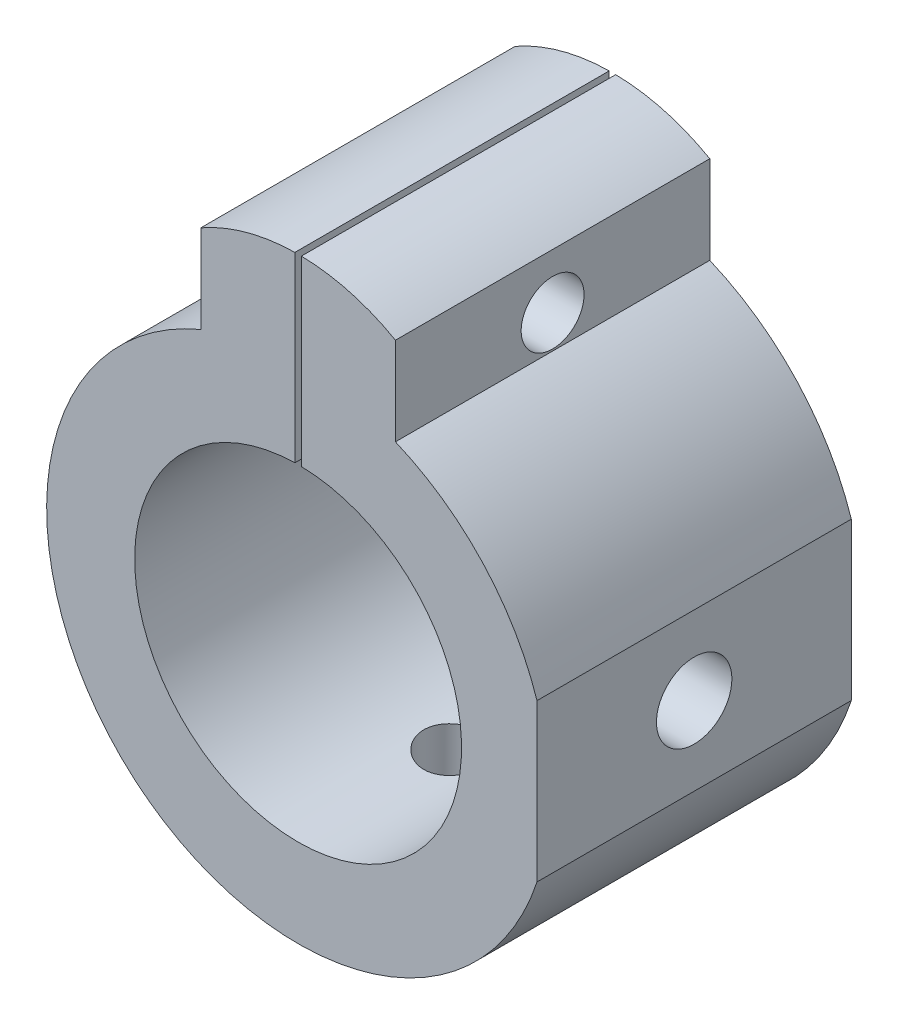
from build123d import *

# Parameters (mm, degrees)
SKETCH_1_R          = 3.5
SKETCH_1_R_2        = 13
EXTRUDE_2_DEPTH     = 10
SKETCH_2_R          = 13
EXTRUDE_3_DEPTH     = 15
SKETCH_3_W          = 0.517195108
SKETCH_3_H          = 18.726193104
CUT_EXTRUDE_1_DEPTH = 26
SKETCH_4_R          = 2.5
CUT_EXTRUDE_2_DEPTH = 43.740275714
CUT_EXTRUDE_3_DEPTH = 11
SKETCH_6_R          = 2.5
CUT_EXTRUDE_4_DEPTH = 21
SKETCH_8_W          = 5
SKETCH_8_H          = 30
CUT_EXTRUDE_5_DEPTH = 26.0000001
SKETCH_9_R          = 3
CUT_EXTRUDE_6_DEPTH = 10


with BuildPart() as part:
    # 草图1 → 凸台-拉伸2 (new body)
    with BuildSketch(Plane.XY):
        with BuildLine():
            Line((-35, -7), (-7.740275714, -18.44147857))
            ThreePointArc((-7.740275714, -18.44147857), (0, -20), (7.740275714, -18.44147857))
            Line((7.740275714, -18.44147857), (35, -7))
            Line((35, -7), (35, 7))
            Line((35, 7), (7.740275714, 18.44147857))
            Line((7.740275714, 18.44147857), (7.740275714, 25.44147857))
            ThreePointArc((7.740275714, 25.44147857), (0, 27.494244152), (-7.740275714, 25.44147857))
            Line((-7.740275714, 25.44147857), (-7.740275714, 18.44147857))
            Line((-7.740275714, 18.44147857), (-35, 7))
            Line((-35, 7), (-35, -7))
        make_face()
        with Locations((-28, 0)):
            Circle(SKETCH_1_R, mode=Mode.SUBTRACT)
        Circle(SKETCH_1_R_2, mode=Mode.SUBTRACT)
        with Locations((28, 0)):
            Circle(SKETCH_1_R, mode=Mode.SUBTRACT)
    extrude(amount=EXTRUDE_2_DEPTH)

    # 草图2 → 凸台-拉伸3 (add)
    with BuildSketch(Plane.XY.offset(10)):
        with BuildLine():
            Line((-7.740275714, 18.44147857), (-7.740275714, 25.44147857))
            ThreePointArc((-7.740275714, 25.44147857), (0, 27.494244152), (7.740275714, 25.44147857))
            Line((7.740275714, 25.44147857), (7.740275714, 18.44147857))
            ThreePointArc((7.740275714, 18.44147857), (0, -20), (-7.740275714, 18.44147857))
        make_face()
        Circle(SKETCH_2_R, mode=Mode.SUBTRACT)
    extrude(amount=EXTRUDE_3_DEPTH)

    # 草图3 → 切除-拉伸1 (cut, through all)
    with BuildSketch(Plane.XY.offset(25)):
        with Locations((0, 21.741202931)):
            Rectangle(SKETCH_3_W, SKETCH_3_H)
    extrude(amount=-CUT_EXTRUDE_1_DEPTH, mode=Mode.SUBTRACT)

    # 草图4 → 切除-拉伸2 (cut, through all)
    with BuildSketch(Plane(origin=(7.740275714, 0, 0), x_dir=(0, 0, -1), z_dir=(1, 0, 0))):
        with Locations((-12.5, 21.086423576)):
            Circle(SKETCH_4_R)
    extrude(amount=-CUT_EXTRUDE_2_DEPTH, mode=Mode.SUBTRACT)

    # 草图5 → 切除-拉伸3 (cut, through all)
    with BuildSketch(Plane.XY.offset(10)):
        with BuildLine():
            Line((-7.740275714, 18.44147857), (-35, 7))
            Line((-35, 7), (-35, -7))
            Line((-35, -7), (-7.740275714, -18.44147857))
            ThreePointArc((-7.740275714, -18.44147857), (-20, 0), (-7.740275714, 18.44147857))
        make_face()
        with BuildLine():
            Line((7.740275714, 18.44147857), (35, 7))
            Line((35, 7), (35, -7))
            Line((35, -7), (7.740275714, -18.44147857))
            ThreePointArc((7.740275714, -18.44147857), (20, 0), (7.740275714, 18.44147857))
        make_face()
    extrude(amount=-CUT_EXTRUDE_3_DEPTH, mode=Mode.SUBTRACT)

    # 草图6 → 切除-拉伸4 (cut, through all)
    with BuildSketch(Plane(origin=(0, 0, 0), x_dir=(1, 0, 0), z_dir=(0, 1, 0))):
        with Locations((0, -12.5)):
            Circle(SKETCH_6_R)
    extrude(amount=-CUT_EXTRUDE_4_DEPTH, mode=Mode.SUBTRACT)

    # 草图8 → 切除-拉伸5 (cut, through all)
    with BuildSketch(Plane.XY):
        with Locations((21.5, 0)):
            Rectangle(SKETCH_8_W, SKETCH_8_H)
    extrude(amount=CUT_EXTRUDE_5_DEPTH, mode=Mode.SUBTRACT)

    # 草图9 → 切除-拉伸6 (cut)
    with BuildSketch(Plane(origin=(19, 0, 0), x_dir=(0, 0, -1), z_dir=(1, 0, 0))):
        with Locations((-12.5, 0)):
            Circle(SKETCH_9_R)
    extrude(amount=-CUT_EXTRUDE_6_DEPTH, mode=Mode.SUBTRACT)


solid = part.part
